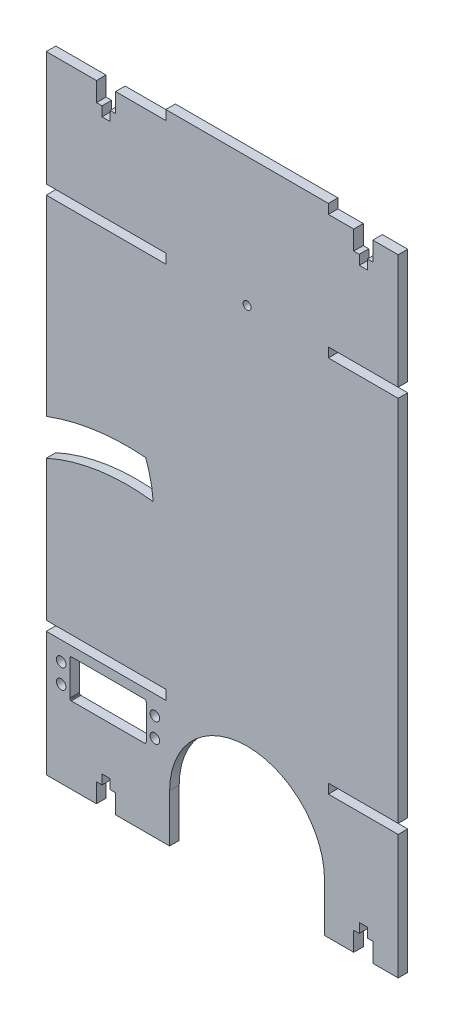
from build123d import *

# Parameters (mm, degrees)
SKETCH2_W           = 184
SKETCH2_H           = 332.5
BOSS_EXTRUDE1_DEPTH = 5
SKETCH3_W           = 62.5
SKETCH3_H           = 5
SKETCH3_W_2         = 36.5
CUT_EXTRUDE2_DEPTH  = 5
CUT_EXTRUDE3_DEPTH  = 10
SKETCH5_R           = 2.1
CUT_EXTRUDE4_DEPTH  = 10
SKETCH6_R           = 2.5
CUT_EXTRUDE5_DEPTH  = 20
CUT_EXTRUDE6_DEPTH  = 10


with BuildPart() as part:
    # Sketch2 → Boss-Extrude1 (new body)
    with BuildSketch(Plane.XY):
        Rectangle(SKETCH2_W, SKETCH2_H)
    extrude(amount=BOSS_EXTRUDE1_DEPTH)

    # Sketch3 → Cut-Extrude2 (cut)
    with BuildSketch(Plane.XY.offset(5)):
        with Locations((-60.75, -98.75)):
            Rectangle(SKETCH3_W, SKETCH3_H)
        with Locations((73.75, -98.75)):
            Rectangle(SKETCH3_W_2, SKETCH3_H)
        with BuildLine():
            Line((-27.5, -141.25), (-27.5, -166.25))
            Line((-27.5, -166.25), (53.5, -166.25))
            Line((53.5, -166.25), (53.5, -141.25))
            ThreePointArc((53.5, -141.25), (13, -100.75), (-27.5, -141.25))
        make_face()
        with Locations((-60.75, 163.75)):
            Rectangle(SKETCH3_W, SKETCH3_H)
        with Locations((73.75, 163.75)):
            Rectangle(SKETCH3_W_2, SKETCH3_H)
        with Locations((-60.75, 98.75)):
            Rectangle(SKETCH3_W, SKETCH3_H)
        with Locations((73.75, 98.75)):
            Rectangle(SKETCH3_W_2, SKETCH3_H)
    extrude(amount=-CUT_EXTRUDE2_DEPTH, mode=Mode.SUBTRACT)

    # Sketch4 → Cut-Extrude3 (cut)
    with BuildSketch(Plane.XY.offset(5)):
        Polygon((-55.75, 161.25), (-55.75, 151.25), (-58.65, 151.25), (-58.65, 146.25), (-62.85, 146.25), (-62.85, 151.25), (-65.75, 151.25), (-65.75, 161.25), align=None)
        Polygon((78.75, 161.25), (78.75, 151.25), (75.85, 151.25), (75.85, 146.25), (71.65, 146.25), (71.65, 151.25), (68.75, 151.25), (68.75, 161.25), align=None)
        Polygon((68.75, -166.25), (68.75, -156.25), (71.65, -156.25), (71.65, -151.25), (75.85, -151.25), (75.85, -156.25), (78.75, -156.25), (78.75, -166.25), align=None)
        Polygon((-65.75, -166.25), (-65.75, -156.25), (-62.85, -156.25), (-62.85, -151.25), (-58.65, -151.25), (-58.65, -156.25), (-55.75, -156.25), (-55.75, -166.25), align=None)
    extrude(amount=-CUT_EXTRUDE3_DEPTH, mode=Mode.SUBTRACT)

    # Sketch5 → Cut-Extrude4 (cut)
    with BuildSketch(Plane.XY.offset(5)):
        with Locations((13, 98.75)):
            Circle(SKETCH5_R)
    extrude(amount=-CUT_EXTRUDE4_DEPTH, mode=Mode.SUBTRACT)

    # Sketch6 → Cut-Extrude5 (cut)
    with BuildSketch(Plane(origin=(0, 0, 0), x_dir=(-1, 0, 0), z_dir=(0, 0, -1))):
        with Locations((35.2, -111.17)):
            Circle(SKETCH6_R)
        with Locations((35.2, -121.33)):
            Circle(SKETCH6_R)
        with Locations((84.2, -121.33)):
            Circle(SKETCH6_R)
        with Locations((84.2, -111.17)):
            Circle(SKETCH6_R)
        Polygon((40.7, -106.25), (40.399667757, -106.296165348), (40.234631653, -106.364882888), (40.087708911, -106.459367581), (39.992893219, -106.542893219), (39.859754352, -106.707794088), (39.773544355, -106.873596044), (39.723897446, -107.032689615), (39.7, -107.25), (39.7, -125.25), (39.821493713, -125.727730786), (39.992893219, -125.957106781), (40.299461949, -126.166280126), (40.7, -126.25), (78.2, -126.25), (78.7, -126.25), (79.000332243, -126.203834652), (79.284083673, -126.061693454), (79.431556814, -125.931780484), (79.678284878, -125.4572648), (79.7, -125.25), (79.7, -107.25), (79.694079498, -107.141344807), (79.68082013, -107.055084963), (79.654773565, -106.952666114), (79.626455645, -106.873596044), (79.58827866, -106.790695066), (79.540245648, -106.707794088), (79.480899769, -106.625343654), (79.431556814, -106.568219516), (79.407106781, -106.542893219), (79.357820244, -106.496825036), (79.297626381, -106.448225275), (79.228612143, -106.401136523), (79.142207958, -106.35308745), (79.088762914, -106.32866217), (79.000332243, -106.296165348), (78.955551566, -106.283204573), (78.853081535, -106.261786438), (78.755064535, -106.251517202), (78.7, -106.25), align=None)
    extrude(amount=-CUT_EXTRUDE5_DEPTH, mode=Mode.SUBTRACT)

    # Sketch7 → Cut-Extrude6 (cut)
    with BuildSketch(Plane(origin=(0, 0, 0), x_dir=(-1, 0, 0), z_dir=(0, 0, -1))):
        with BuildLine():
            Line((92.154047247, -4.010729367), (92, -22.885338591))
            ThreePointArc((92, -22.885338591), (64.618518363, -14.841480585), (36.080546525, -14.658856257))
            ThreePointArc((36.080546525, -14.658856257), (37.397553955, -5.515336457), (39.976105832, 3.355375641))
            ThreePointArc((39.976105832, 3.355375641), (66.474403295, 2.571796797), (92.154047247, -4.010729367))
        make_face()
    extrude(amount=-CUT_EXTRUDE6_DEPTH, mode=Mode.SUBTRACT)


solid = part.part
